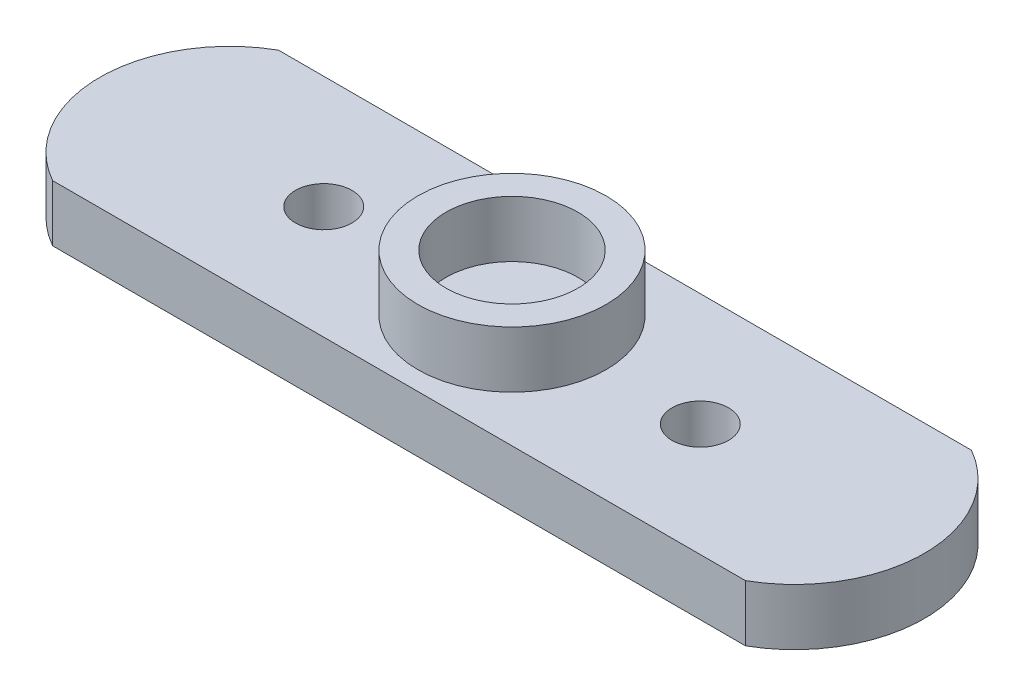
from build123d import *

# Parameters (mm, degrees)
SKETCH1_R           = 1.5025
BOSS_EXTRUDE1_DEPTH = 3
SKETCH2_R           = 5
SKETCH2_R_2         = 3.5025
BOSS_EXTRUDE2_DEPTH = 3


with BuildPart() as part:
    # Sketch1 → Boss-Extrude1 (new body)
    with BuildSketch(Plane(origin=(0, 0, 0), x_dir=(1, 0, 0), z_dir=(0, 1, 0))):
        with BuildLine():
            Line((-18.4, 6), (18.4, 6))
            ThreePointArc((18.4, 6), (21.9, 0), (18.4, -6))
            Line((18.4, -6), (-18.4, -6))
            ThreePointArc((-18.4, -6), (-21.9, 0), (-18.4, 6))
        make_face()
        with Locations((10, 0)):
            Circle(SKETCH1_R, mode=Mode.SUBTRACT)
        with Locations((-10, 0)):
            Circle(SKETCH1_R, mode=Mode.SUBTRACT)
    extrude(amount=BOSS_EXTRUDE1_DEPTH)

    # Sketch2 → Boss-Extrude2 (add)
    with BuildSketch(Plane(origin=(0, 3, 0), x_dir=(1, 0, 0), z_dir=(0, 1, 0))):
        Circle(SKETCH2_R)
        Circle(SKETCH2_R_2, mode=Mode.SUBTRACT)
    extrude(amount=BOSS_EXTRUDE2_DEPTH)


solid = part.part
